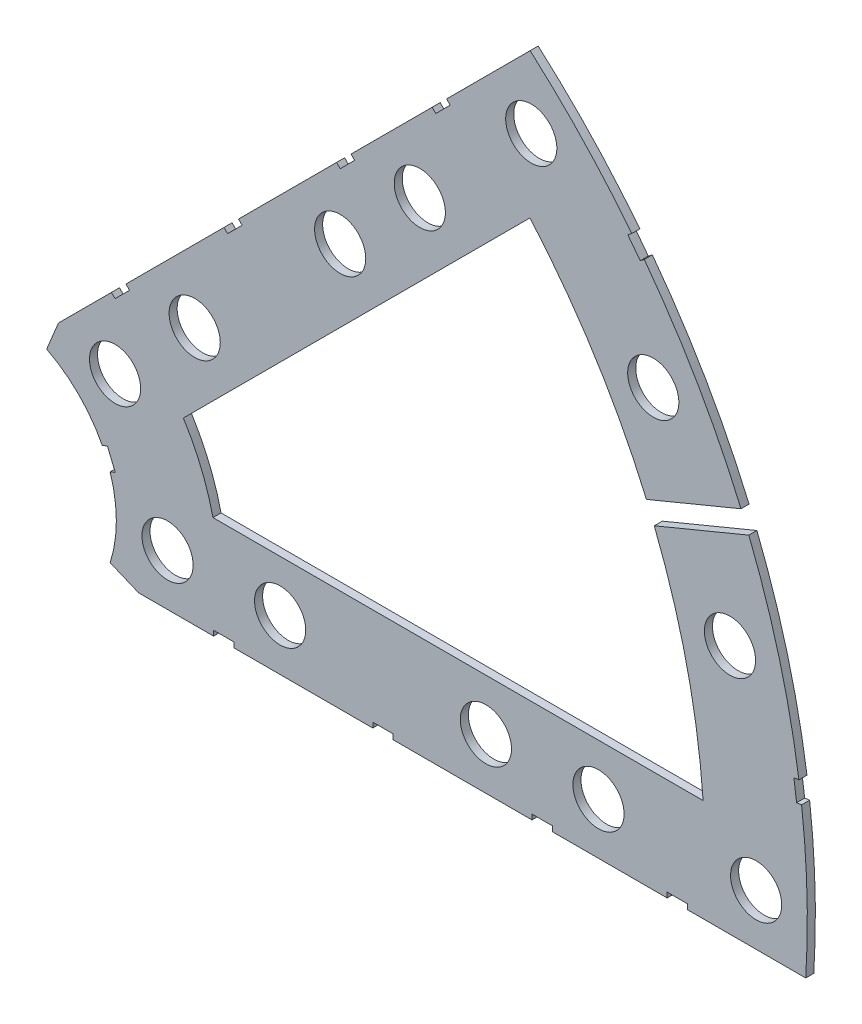
from build123d import *

# Parameters (mm, degrees)
BOSS_EXTRUDE1_DEPTH = 1
SKETCH2_R           = 3.175
CUT_EXTRUDE1_DEPTH  = 2
SKETCH3_W           = 2.54
SKETCH3_H           = 0.635
CUT_EXTRUDE2_DEPTH  = 2


with BuildPart() as part:
    # Sketch1 → Boss-Extrude1 (new body)
    with BuildSketch(Plane.XY):
        with BuildLine():
            Line((67.21146711, 76.191723231), (8.696654013, 17.676910134))
            Line((8.696654013, 17.676910134), (7.228954972, 14.133571205))
            ThreePointArc((7.228954972, 14.133571205), (14.666587579, 6.075099489), (15.105587123, -4.88230096))
            Line((15.105587123, -4.88230096), (18.648926052, -6.35))
            Line((18.648926052, -6.35), (101.401368334, -6.35))
            ThreePointArc((101.401368334, -6.35), (93.866160503, 38.880636728), (67.21146711, 76.191723231))
        make_face()
        with BuildLine():
            Line((88.672924278, 6.35), (27.86051193, 6.35))
            ThreePointArc((27.86051193, 6.35), (26.399857642, 10.93517908), (24.190484974, 15.210228852))
            Line((24.190484974, 15.210228852), (67.191354125, 58.211098004))
            ThreePointArc((67.191354125, 58.211098004), (82.13289044, 34.020557137), (88.672924278, 6.35))
        make_face(mode=Mode.SUBTRACT)
    extrude(amount=BOSS_EXTRUDE1_DEPTH)

    # Sketch2 → Cut-Extrude1 (cut, through all)
    with BuildSketch(Plane.XY.offset(1)):
        with Locations((22.225, 0)):
            Circle(SKETCH2_R)
        with Locations((36.195, 0)):
            Circle(SKETCH2_R)
        with Locations((61.722, 0)):
            Circle(SKETCH2_R)
        with Locations((75.692, 0)):
            Circle(SKETCH2_R)
        with Locations((95.25, 0)):
            Circle(SKETCH2_R)
        with Locations((15.715448212, 15.715448212)):
            Circle(SKETCH2_R)
        with Locations((25.593729945, 25.593729945)):
            Circle(SKETCH2_R)
        with Locations((43.644044748, 43.644044748)):
            Circle(SKETCH2_R)
        with Locations((53.522326482, 53.522326482)):
            Circle(SKETCH2_R)
        with Locations((92.004434954, 24.652514046)):
            Circle(SKETCH2_R)
        with Locations((82.48891971, 47.625)):
            Circle(SKETCH2_R)
        with Locations((67.351920908, 67.351920908)):
            Circle(SKETCH2_R)
    extrude(amount=-CUT_EXTRUDE1_DEPTH, mode=Mode.SUBTRACT)

    # Sketch3 → Cut-Extrude2 (cut, through all)
    with BuildSketch(Plane.XY.offset(1)):
        Polygon((15.266435406, 24.246691527), (17.06248663, 26.042742751), (17.511499436, 25.593729945), (15.715448212, 23.797678721), align=None)
        Polygon((44.991083167, 53.971339288), (43.195031942, 52.175288063), (43.644044748, 51.726275257), (45.440095973, 53.522326482), align=None)
        with Locations((29.21, -6.0325)):
            Rectangle(SKETCH3_W, SKETCH3_H)
        with Locations((68.707, -6.0325)):
            Rectangle(SKETCH3_W, SKETCH3_H)
        Polygon((29.230733674, 38.210989795), (31.026784898, 40.007041019), (31.475797704, 39.558028213), (29.67974648, 37.761976989), align=None)
        Polygon((56.845021246, 65.825277367), (55.048970022, 64.029226143), (55.497982828, 63.580213337), (57.294034052, 65.376264561), align=None)
        with Locations((48.9585, -6.0325)):
            Rectangle(SKETCH3_W, SKETCH3_H)
        with Locations((85.471, -6.0325)):
            Rectangle(SKETCH3_W, SKETCH3_H)
        Polygon((99.935462164, 14.437711971), (100.266998693, 11.919442024), (101.526133667, 12.085210288), (101.194597138, 14.603480236), align=None)
        Polygon((94.55347955, 40.539971694), (95.525495469, 38.193317681), (81.445571393, 32.361222172), (80.473555475, 34.707876184), align=None)
        Polygon((79.327792988, 62.471156422), (80.874047017, 60.456038938), (81.88160576, 61.229165953), (80.33535173, 63.244283437), align=None)
        Polygon((13.593916116, 7.005422516), (14.565932035, 4.658768503), (15.739259041, 5.144776462), (14.767243123, 7.491430475), align=None)
    extrude(amount=-CUT_EXTRUDE2_DEPTH, mode=Mode.SUBTRACT)


solid = part.part
